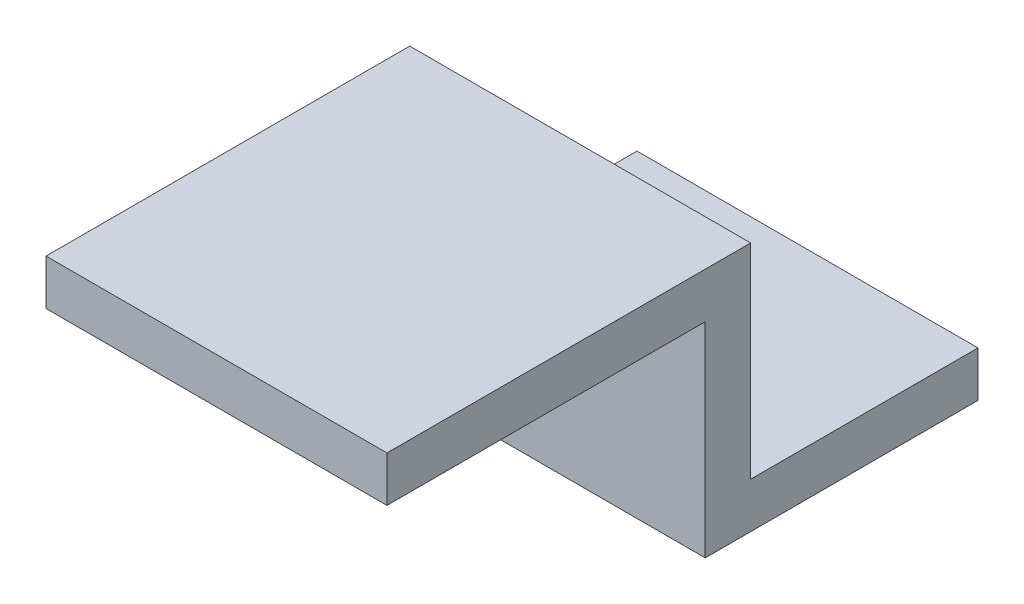
from build123d import *

# Parameters (mm, degrees)
BOSS_EXTRUDE1_DEPTH = 15
CUT_EXTRUDE1_REACH  = 4
SKETCH3_R           = 1.5


with BuildPart() as part:
    # Sketch1 → Boss-Extrude1 (new body)
    with BuildSketch(Plane(origin=(0, 0, 0), x_dir=(0, 0, -1), z_dir=(1, 0, 0))):
        Polygon((0, 0), (16, 0), (16, -9), (26, -9), (26, -11), (14, -11), (14, -2), (0, -2), align=None)
    extrude(amount=-BOSS_EXTRUDE1_DEPTH)

    # Sketch3 → Cut-Extrude1 (cut, up to next)
    with BuildSketch(Plane(origin=(0, -9, 0), x_dir=(1, 0, 0), z_dir=(0, 1, 0)), mode=Mode.PRIVATE) as cut_extrude1_sk1:
        with Locations((-7.5, 21)):
            Circle(SKETCH3_R)
    cut_extrude1_tool1 = extrude(cut_extrude1_sk1.sketch, amount=-CUT_EXTRUDE1_REACH, mode=Mode.PRIVATE) & part.part
    add(cut_extrude1_tool1.solids().sort_by_distance((-7.5, -9, -21))[0], mode=Mode.SUBTRACT)


solid = part.part
